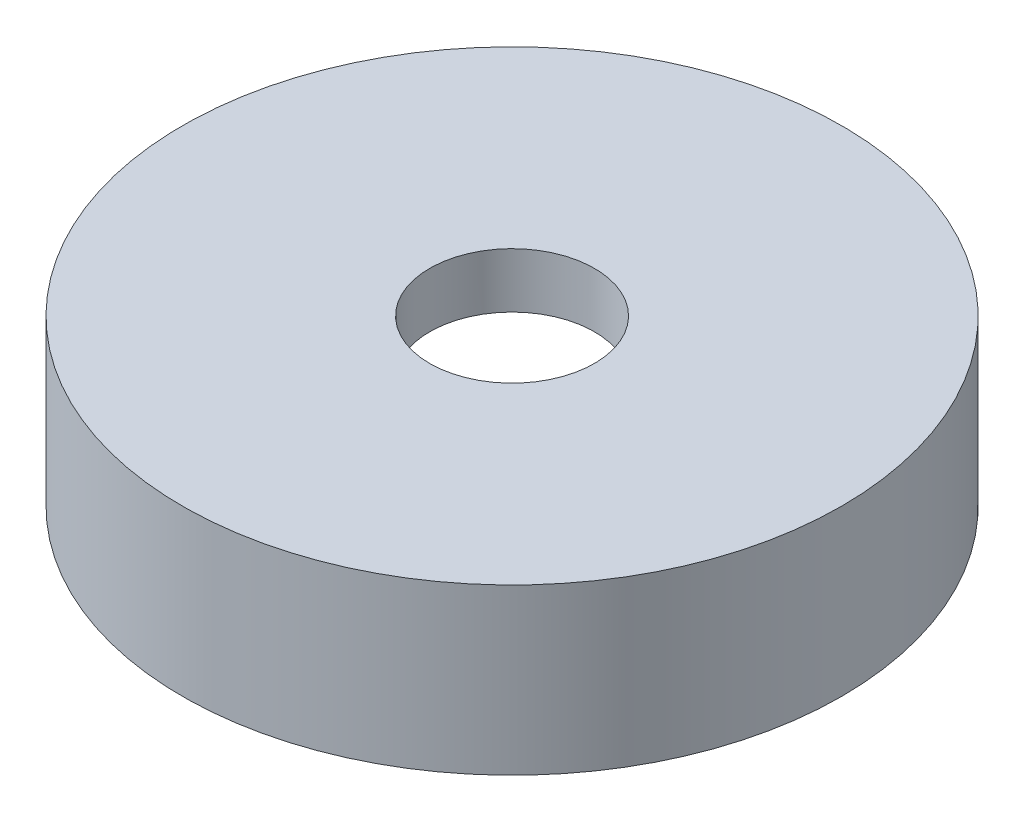
from build123d import *

# Parameters (mm, degrees)
F_3_0MM_DOWEL_HOLE1_D     = 3
F_3_0MM_DOWEL_HOLE1_DEPTH = 7.598709071
F_3_0MM_DOWEL_HOLE1_TIP   = 0.901290929


with BuildPart() as part:
    # Sketch1 → Revolve1 (revolve)
    with BuildSketch(Plane.XY):
        Polygon((0, 3), (6, 3), (6, 0), (5, 0), (5, 2), (0, 2), align=None)
    revolve(axis=Axis((0, 0, 0), (0, 1, 0)))

    # Ø3.0mm Dowel Hole1
    with Locations(Plane(origin=(0, 3, 0), x_dir=(1, 0, 0), z_dir=(0, 1, 0))):
        with Locations((0, 0)):
            Hole(F_3_0MM_DOWEL_HOLE1_D / 2, depth=F_3_0MM_DOWEL_HOLE1_DEPTH)
            with Locations((0, 0, -(F_3_0MM_DOWEL_HOLE1_DEPTH + F_3_0MM_DOWEL_HOLE1_TIP / 2))):  # 118° drill point
                Cone(0, F_3_0MM_DOWEL_HOLE1_D / 2, F_3_0MM_DOWEL_HOLE1_TIP, mode=Mode.SUBTRACT)


solid = part.part
